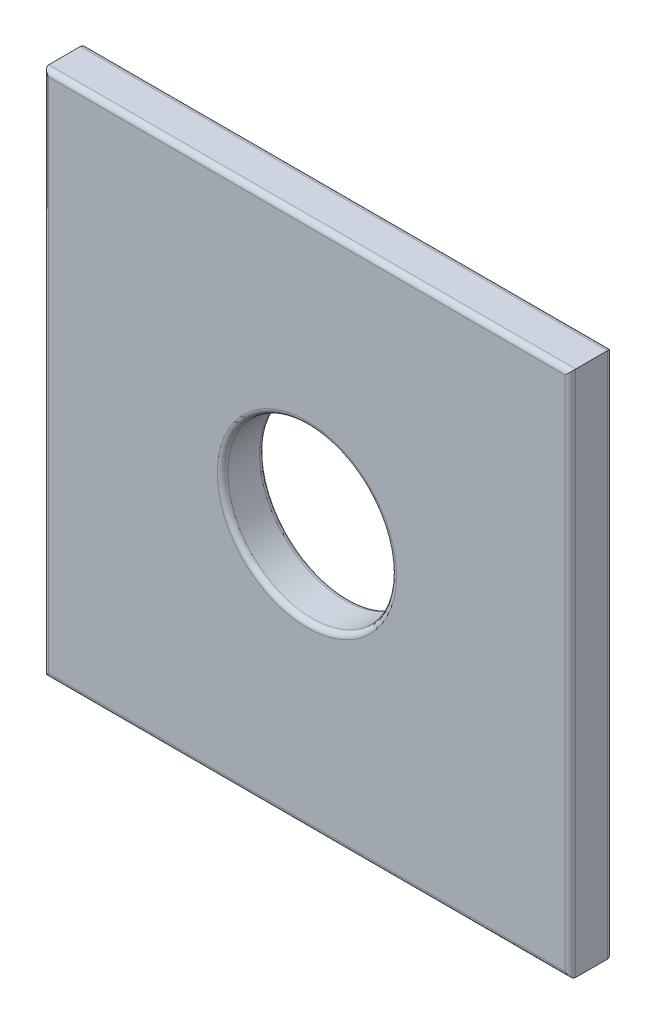
from build123d import *

# Parameters (mm, degrees)
SZKIC1_W                    = 50
SZKIC1_H                    = 50
SZKIC1_R                    = 8
DODANIE_WYCI_GNI_CIE1_DEPTH = 4
ZAOKR_GLENIE1_R             = 0.5


with BuildPart() as part:
    # Szkic1 → Dodanie-wyciągnięcie1 (new body)
    with BuildSketch(Plane.XY):
        with Locations((-1030.555795761, -150.582176964)):
            Rectangle(SZKIC1_W, SZKIC1_H)
        with Locations((-1030.555795761, -150.582176964)):
            Circle(SZKIC1_R, mode=Mode.SUBTRACT)
    extrude(amount=DODANIE_WYCI_GNI_CIE1_DEPTH)

    # Zaokrąglenie1
    zaokr_glenie1_edges = [part.edges().sort_by_distance(p)[0] for p in [
        (-1005.555795761, -150.582176964, 4),
        (-1030.555795761, -125.582176964, 4),
        (-1055.555795761, -150.582176964, 4),
        (-1030.555795761, -175.582176964, 4),
        (-1038.555795761, -150.582176964, 4),
        (-1030.555795761, -175.582176964, 0),
        (-1055.555795761, -150.582176964, 0),
        (-1030.555795761, -125.582176964, 0),
        (-1005.555795761, -150.582176964, 0),
        (-1038.555795761, -150.582176964, 0),
    ]]
    fillet(zaokr_glenie1_edges, radius=ZAOKR_GLENIE1_R)


solid = part.part
